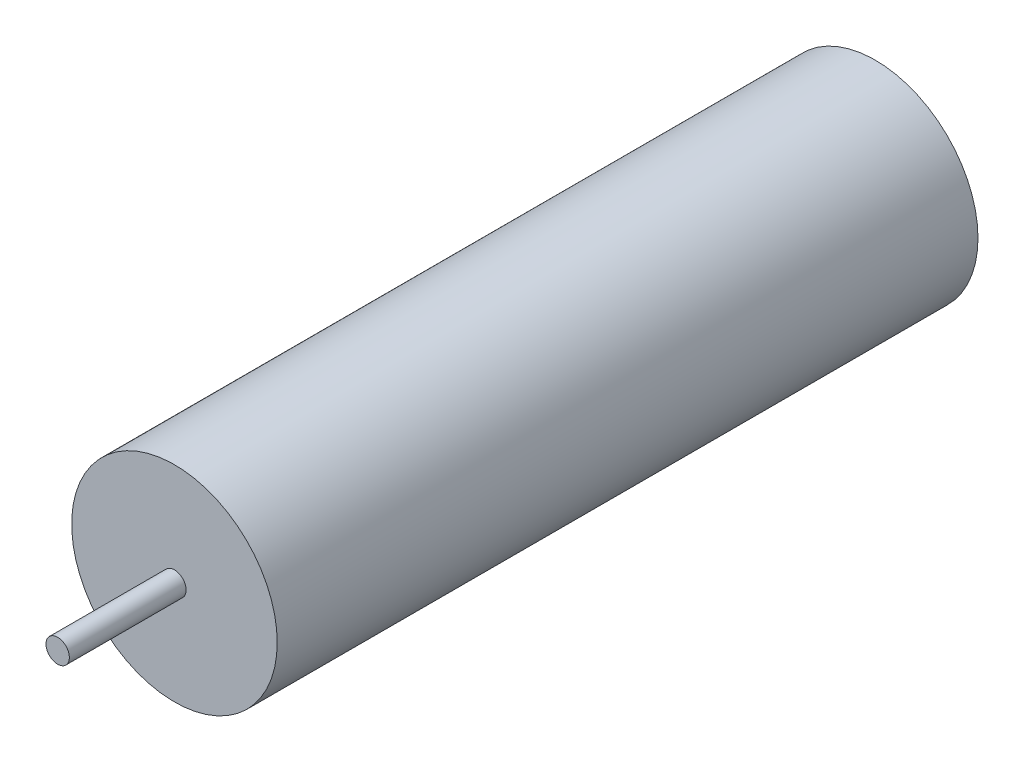
from build123d import *

# Parameters (mm, degrees)
SKETCH1_R           = 11.176
BOSS_EXTRUDE1_DEPTH = 76.2
SKETCH2_R           = 1.27
BOSS_EXTRUDE2_DEPTH = 12.7


with BuildPart() as part:
    # Sketch1 → Boss-Extrude1 (new body)
    with BuildSketch(Plane.XY):
        with Locations((0, -25.4)):
            Circle(SKETCH1_R)
    extrude(amount=-BOSS_EXTRUDE1_DEPTH)

    # Sketch2 → Boss-Extrude2 (add)
    with BuildSketch(Plane.XY):
        with Locations((0, -25.4)):
            Circle(SKETCH2_R)
    extrude(amount=BOSS_EXTRUDE2_DEPTH)


solid = part.part
